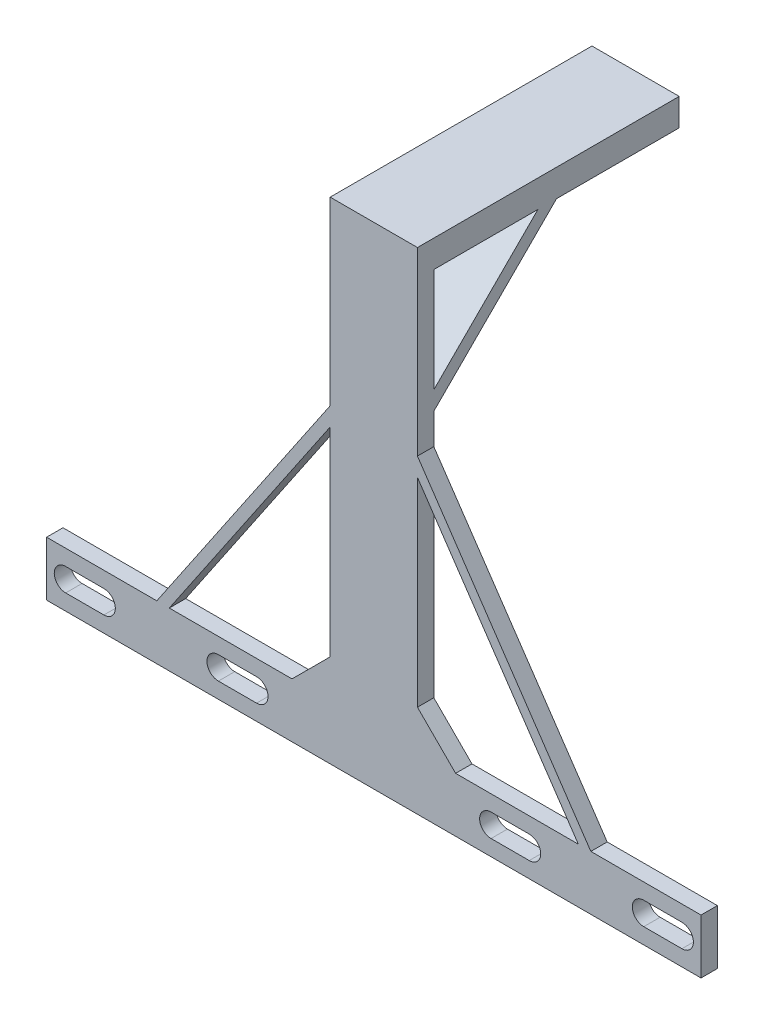
from build123d import *

# Parameters (mm, degrees)
BOSS_EXTRUDE1_DEPTH = 3
CUT_EXTRUDE1_DEPTH  = 3
SKETCH4_W           = 16
SKETCH4_H           = 5
BOSS_EXTRUDE2_DEPTH = 45
BOSS_EXTRUDE3_DEPTH = 16
SKETCH8_W           = 0.849028348
SKETCH8_H           = 44.071161876
SKETCH8_W_2         = 1.029765792
BOSS_EXTRUDE4_DEPTH = 1
BOSS_EXTRUDE5_DEPTH = 3


with BuildPart() as part:
    # Sketch1 → Boss-Extrude1 (new body)
    with BuildSketch(Plane.XY):
        Polygon((0, 0), (120, 0), (120, 10), (75, 10), (68, 17), (68, 40), (68, 90), (52, 90), (52, 40), (52, 17), (45, 10), (0, 10), align=None)
    extrude(amount=BOSS_EXTRUDE1_DEPTH)

    # Sketch2 → Cut-Extrude1 (cut)
    with BuildSketch(Plane.XY.offset(3)):
        with BuildLine():
            Line((3.5, 7.1), (10.5, 7.1))
            ThreePointArc((10.5, 7.1), (12.6, 5), (10.5, 2.9))
            Line((10.5, 2.9), (3.5, 2.9))
            ThreePointArc((3.5, 2.9), (1.4, 5), (3.5, 7.1))
        make_face()
        with BuildLine():
            Line((31.5, 7.1), (38.5, 7.1))
            ThreePointArc((38.5, 7.1), (40.6, 5), (38.5, 2.9))
            Line((38.5, 2.9), (31.5, 2.9))
            ThreePointArc((31.5, 2.9), (29.4, 5), (31.5, 7.1))
        make_face()
        with BuildLine():
            Line((81.5, 7.1), (88.5, 7.1))
            ThreePointArc((88.5, 7.1), (90.6, 5), (88.5, 2.9))
            Line((88.5, 2.9), (81.5, 2.9))
            ThreePointArc((81.5, 2.9), (79.4, 5), (81.5, 7.1))
        make_face()
        with BuildLine():
            Line((116.5, 2.9), (109.5, 2.9))
            ThreePointArc((109.5, 2.9), (107.4, 5), (109.5, 7.1))
            Line((109.5, 7.1), (116.5, 7.1))
            ThreePointArc((116.5, 7.1), (118.6, 5), (116.5, 2.9))
        make_face()
    extrude(amount=-CUT_EXTRUDE1_DEPTH, mode=Mode.SUBTRACT)

    # Sketch4 → Boss-Extrude2 (add)
    with BuildSketch(Plane(origin=(0, 0, 0), x_dir=(-1, 0, 0), z_dir=(0, 0, -1))):
        with Locations((-60, 87.5)):
            Rectangle(SKETCH4_W, SKETCH4_H)
    extrude(amount=BOSS_EXTRUDE2_DEPTH)

    # Sketch7 → Boss-Extrude3 (add)
    with BuildSketch(Plane.ZY.offset(-52)):
        Polygon((-22.5, 85), (0, 62.5), (0, 65.90318292), (-19.09681708, 85), align=None)
    extrude(amount=-BOSS_EXTRUDE3_DEPTH)

    # Sketch8 → Boss-Extrude4 (add)
    with BuildSketch(Plane(origin=(0, 0, 0), x_dir=(-1, 0, 0), z_dir=(0, 0, -1))):
        with Locations((-56.917783528, 39.035580938)):
            Rectangle(SKETCH8_W, SKETCH8_H)
        with Locations((-63.407411106, 39.035580938)):
            Rectangle(SKETCH8_W_2, SKETCH8_H)
    extrude(amount=BOSS_EXTRUDE4_DEPTH)

    # Sketch9 → Boss-Extrude5 (add)
    with BuildSketch(Plane.XY.offset(3)):
        Polygon((22.5, 10), (52, 53.5), (52, 56.880398444), (20.207545882, 10), align=None)
        Polygon((97.5, 10), (68, 53.5), (68, 56.880398444), (99.792454118, 10), align=None)
    extrude(amount=-BOSS_EXTRUDE5_DEPTH)


solid = part.part
